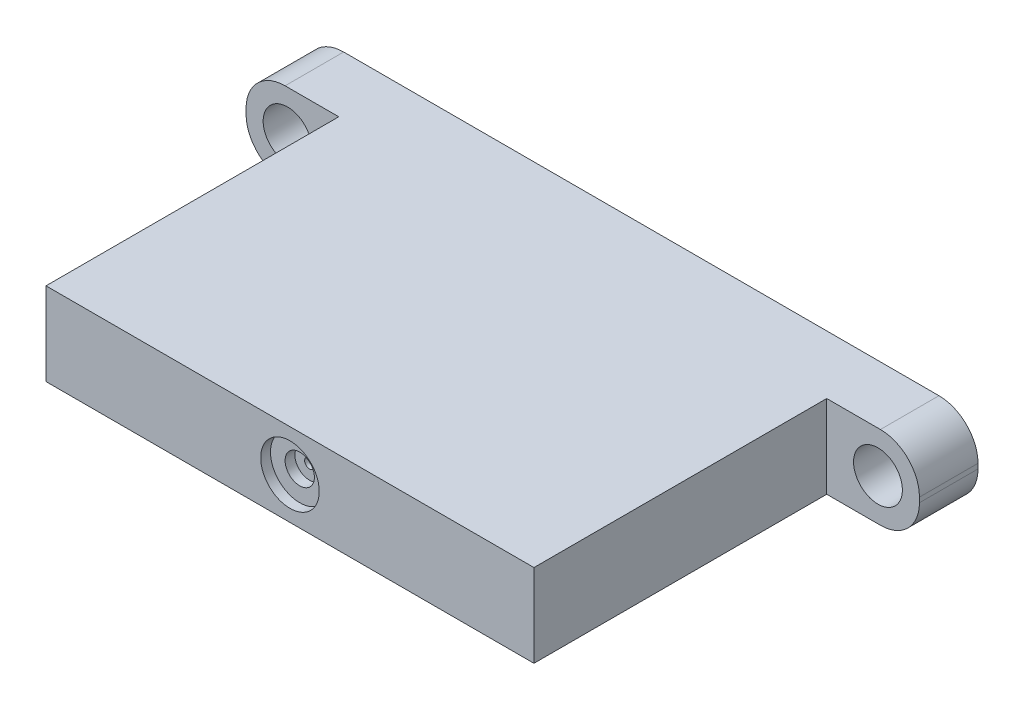
from build123d import *

# Parameters (mm, degrees)
ESBO_O1_W                = 69
ESBO_O1_H                = 8.5
RESSALTO_EXTRUS_O1_DEPTH = 6
ESBO_O2_W                = 50
ESBO_O2_H                = 8.5
RESSALTO_EXTRUS_O2_DEPTH = 30
ESBO_O3_R                = 2.5
CORTE_EXTRUS_O1_DEPTH    = 7
FILETE1_R                = 4
ESBO_O4_R                = 3
CORTE_EXTRUS_O2_DEPTH    = 1
ESBO_O5_R                = 1.5
CORTE_EXTRUS_O3_DEPTH    = 1
ESBO_O6_R                = 0.5
CORTE_EXTRUS_O4_DEPTH    = 1


with BuildPart() as part:
    # Esboço1 → Ressalto-extrusão1 (new body)
    with BuildSketch(Plane.XY):
        Rectangle(ESBO_O1_W, ESBO_O1_H)
    extrude(amount=RESSALTO_EXTRUS_O1_DEPTH)

    # Esboço2 → Ressalto-extrusão2 (add)
    with BuildSketch(Plane.XY.offset(6)):
        Rectangle(ESBO_O2_W, ESBO_O2_H)
    extrude(amount=RESSALTO_EXTRUS_O2_DEPTH)

    # Esboço3 → Corte-extrusão1 (cut, through all)
    with BuildSketch(Plane.XY.offset(6)):
        with Locations((-30.25, 0)):
            Circle(ESBO_O3_R)
        with Locations((30.25, 0)):
            Circle(ESBO_O3_R)
    extrude(amount=-CORTE_EXTRUS_O1_DEPTH, mode=Mode.SUBTRACT)

    # Filete1
    filete1_edges = [part.edges().sort_by_distance(p)[0] for p in [
        (-34.5, 4.25, 3),
        (34.5, 4.25, 3),
        (34.5, -4.25, 3),
        (-34.5, -4.25, 3),
    ]]
    fillet(filete1_edges, radius=FILETE1_R)

    # Esboço4 → Corte-extrusão2 (cut)
    with BuildSketch(Plane.XY.offset(36)):
        Circle(ESBO_O4_R)
    extrude(amount=-CORTE_EXTRUS_O2_DEPTH, mode=Mode.SUBTRACT)

    # Esboço5 → Corte-extrusão3 (cut)
    with BuildSketch(Plane.XY.offset(35)):
        Circle(ESBO_O5_R)
    extrude(amount=-CORTE_EXTRUS_O3_DEPTH, mode=Mode.SUBTRACT)

    # Esboço6 → Corte-extrusão4 (cut)
    with BuildSketch(Plane.XY.offset(34)):
        Circle(ESBO_O6_R)
    extrude(amount=-CORTE_EXTRUS_O4_DEPTH, mode=Mode.SUBTRACT)


solid = part.part
